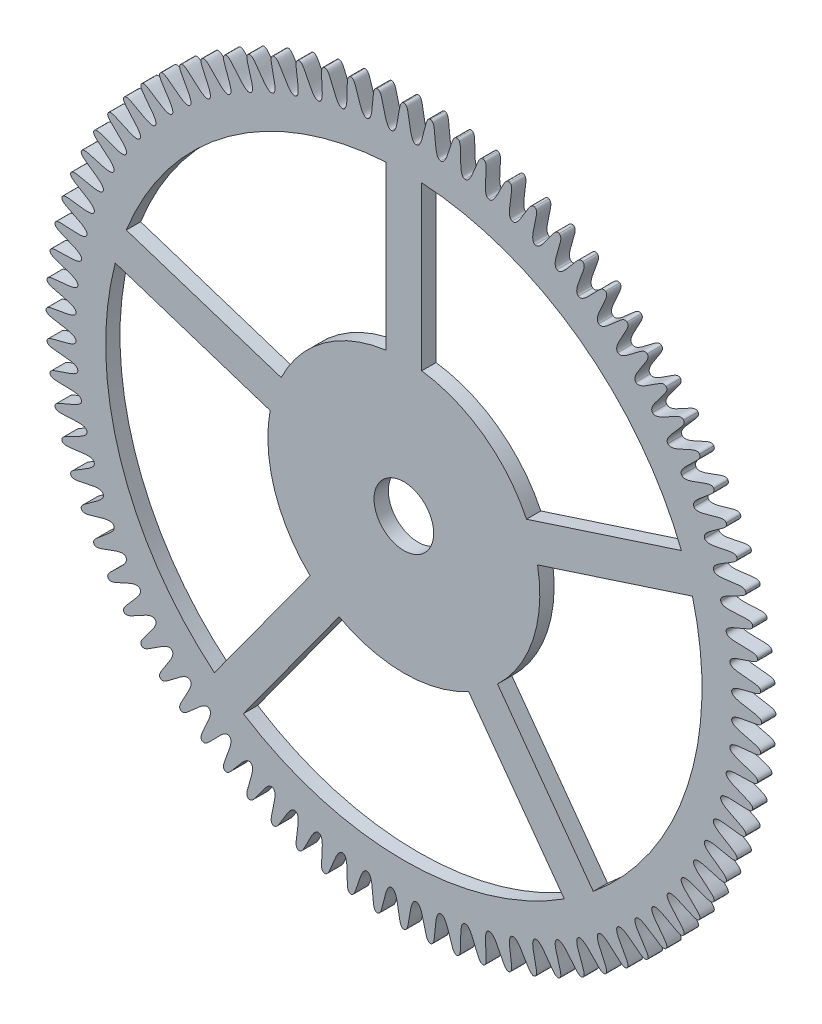
from build123d import *

# Parameters (mm, degrees)
BOSS_EXTRUDE1_84_TEETH_DEPTH = 0.24
CUT_EXTRUDE1_REACH           = 2.24
SKETCH2_R                    = 0.5


with BuildPart() as part:
    # Sketch1 → Boss-Extrude1 (84 teeth) (new body)
    with BuildSketch(Plane.XY):
        with BuildLine():
            add(Edge.make_bspline(
                [(0, 6), (0.062405482, 5.99994907), (0.073251994, 5.870714919), (0.116278173, 5.617573118), (0.146866227, 5.497572533), (0.205718544, 5.497943824)],
                knots=[0, 0, 0, 0, 0.435078789, 0.535078789, 1, 1, 1, 1], degree=3))
            add(Edge.make_bspline(
                [(0.448380562, 5.983222783), (0.386145772, 5.987835563), (0.365671908, 5.859773338), (0.303848729, 5.610554723), (0.264378551, 5.493175532), (0.205718544, 5.497943824)],
                knots=[0, 0, 0, 0, 0.435078789, 0.535078789, 1, 1, 1, 1], degree=3))
            add(Edge.make_bspline(
                [(0.448380562, 5.983222783), (0.510607739, 5.978508428), (0.511766242, 5.848825081), (0.535754801, 5.593175765), (0.557289669, 5.471224878), (0.616005169, 5.467197092)],
                knots=[0, 0, 0, 0, 0.435078789, 0.535078789, 1, 1, 1, 1], degree=3))
            add(Edge.make_bspline(
                [(0.894253597, 5.932984957), (0.832537542, 5.942235651), (0.802550825, 5.816061527), (0.722276386, 5.57215983), (0.674144817, 5.458058465), (0.616005169, 5.467197092)],
                knots=[0, 0, 0, 0, 0.435078789, 0.535078789, 1, 1, 1, 1], degree=3))
            add(Edge.make_bspline(
                [(0.894253597, 5.932984957), (0.955954471, 5.923633542), (0.947418486, 5.79422624), (0.95223527, 5.537499105), (0.964596521, 5.414279915), (1.022846844, 5.405875576)],
                knots=[0, 0, 0, 0, 0.435078789, 0.535078789, 1, 1, 1, 1], degree=3))
            add(Edge.make_bspline(
                [(1.335125604, 5.849567473), (1.274273425, 5.863404346), (1.234941553, 5.739823941), (1.13666478, 5.502603159), (1.080140991, 5.392417722), (1.022846844, 5.405875576)],
                knots=[0, 0, 0, 0, 0.435078789, 0.535078789, 1, 1, 1, 1], degree=3))
            add(Edge.make_bspline(
                [(1.335125604, 5.849567473), (1.395955117, 5.835631294), (1.377772381, 5.707223737), (1.363390454, 5.450854503), (1.366508958, 5.327056102), (1.423968345, 5.314322211)],
                knots=[0, 0, 0, 0, 0.435078789, 0.535078789, 1, 1, 1, 1], degree=3))
            add(Edge.make_bspline(
                [(1.768531046, 5.733436835), (1.708883053, 5.751782506), (1.660425986, 5.631486931), (1.544696484, 5.402273699), (1.480096579, 5.296620391), (1.423968345, 5.314322211)],
                knots=[0, 0, 0, 0, 0.435078789, 0.535078789, 1, 1, 1, 1], degree=3))
            add(Edge.make_bspline(
                [(1.768531046, 5.733436835), (1.828149016, 5.714993829), (1.800421214, 5.588304123), (1.766921005, 5.333726513), (1.760779323, 5.21004123), (1.817126437, 5.193049001)],
                knots=[0, 0, 0, 0, 0.435078789, 0.535078789, 1, 1, 1, 1], degree=3))
            add(Edge.make_bspline(
                [(2.192046146, 5.585242492), (2.133935915, 5.607994365), (2.076624644, 5.491656362), (1.944089618, 5.271732533), (1.871774866, 5.17120221), (1.817126437, 5.193049001)],
                knots=[0, 0, 0, 0, 0.435078789, 0.535078789, 1, 1, 1, 1], degree=3))
            add(Edge.make_bspline(
                [(2.192046146, 5.585242492), (2.250119164, 5.5623958), (2.213001361, 5.438132445), (2.160570216, 5.186770159), (2.145202696, 5.063889695), (2.20012242, 5.042734154)],
                knots=[0, 0, 0, 0, 0.435078789, 0.535078789, 1, 1, 1, 1], degree=3))
            add(Edge.make_bspline(
                [(2.603302435, 5.405813207), (2.547054941, 5.432844045), (2.481209974, 5.321114223), (2.332610615, 5.111709701), (2.252985429, 5.016864569), (2.20012242, 5.042734154)],
                knots=[0, 0, 0, 0, 0.435078789, 0.535078789, 1, 1, 1, 1], degree=3))
            add(Edge.make_bspline(
                [(2.603302435, 5.405813207), (2.659505734, 5.378690597), (2.613205507, 5.257548525), (2.542136643, 5.010807284), (2.517629225, 4.889418834), (2.570814427, 4.864218292)],
                knots=[0, 0, 0, 0, 0.435078789, 0.535078789, 1, 1, 1, 1], degree=3))
            add(Edge.make_bspline(
                [(3, 5.196152423), (2.945929802, 5.227311057), (2.871919371, 5.120814255), (2.708086707, 4.923100114), (2.621596383, 4.834470586), (2.570814427, 4.864218292)],
                knots=[0, 0, 0, 0, 0.435078789, 0.535078789, 1, 1, 1, 1], degree=3))
            add(Edge.make_bspline(
                [(3, 5.196152423), (3.054019268, 5.164905575), (2.998795547, 5.047562261), (2.909486411, 4.806821941), (2.87597615, 4.68760436), (2.927129397, 4.658499748)],
                knots=[0, 0, 0, 0, 0.435078789, 0.535078789, 1, 1, 1, 1], degree=3))
            add(Edge.make_bspline(
                [(3.379920348, 4.957432646), (3.32832983, 4.992544825), (3.246567831, 4.891876617), (3.068418079, 4.706958555), (2.975546308, 4.625040283), (2.927129397, 4.658499748)],
                knots=[0, 0, 0, 0, 0.435078789, 0.535078789, 1, 1, 1, 1], degree=3))
            add(Edge.make_bspline(
                [(3.379920348, 4.957432646), (3.431453488, 4.922236306), (3.367615107, 4.809347981), (3.26056515, 4.5759549), (3.21823945, 4.4595749), (3.267074672, 4.426728984)],
                knots=[0, 0, 0, 0, 0.435078789, 0.535078789, 1, 1, 1, 1], degree=3))
            add(Edge.make_bspline(
                [(3.740938811, 4.690988895), (3.692116487, 4.729858258), (3.603060166, 4.63558162), (3.411589613, 4.464493774), (3.31285577, 4.389744878), (3.267074672, 4.426728984)],
                knots=[0, 0, 0, 0, 0.435078789, 0.535078789, 1, 1, 1, 1], degree=3))
            add(Edge.make_bspline(
                [(3.740938811, 4.690988895), (3.789697627, 4.652039895), (3.717601597, 4.544237877), (3.593409487, 4.319497263), (3.542505049, 4.206605689), (3.588749139, 4.170202156)],
                knots=[0, 0, 0, 0, 0.435078789, 0.535078789, 1, 1, 1, 1], degree=3))
            add(Edge.make_bspline(
                [(4.081036427, 4.398311231), (4.03525533, 4.440720404), (3.939402727, 4.35336257), (3.735682154, 4.197061733), (3.631638399, 4.129900239), (3.588749139, 4.170202156)],
                knots=[0, 0, 0, 0, 0.435078789, 0.535078789, 1, 1, 1, 1], degree=3))
            add(Edge.make_bspline(
                [(4.081036427, 4.398311231), (4.126748241, 4.355827389), (4.046797751, 4.253714551), (3.90615802, 4.038883246), (3.846959523, 3.930111433), (3.890353866, 3.890353866)],
                knots=[0, 0, 0, 0, 0.435078789, 0.535078789, 1, 1, 1, 1], degree=3))
            add(Edge.make_bspline(
                [(4.398311231, 4.081036427), (4.355827389, 4.126748241), (4.253714551, 4.046797751), (4.038883246, 3.90615802), (3.930111433, 3.846959523), (3.890353866, 3.890353866)],
                knots=[0, 0, 0, 0, 0.435078789, 0.535078789, 1, 1, 1, 1], degree=3))
            add(Edge.make_bspline(
                [(4.398311231, 4.081036427), (4.440720404, 4.03525533), (4.35336257, 3.939402727), (4.197061733, 3.735682154), (4.129900239, 3.631638399), (4.170202156, 3.588749139)],
                knots=[0, 0, 0, 0, 0.435078789, 0.535078789, 1, 1, 1, 1], degree=3))
            add(Edge.make_bspline(
                [(4.690988895, 3.740938811), (4.652039895, 3.789697627), (4.544237877, 3.717601597), (4.319497263, 3.593409487), (4.206605689, 3.542505049), (4.170202156, 3.588749139)],
                knots=[0, 0, 0, 0, 0.435078789, 0.535078789, 1, 1, 1, 1], degree=3))
            add(Edge.make_bspline(
                [(4.690988895, 3.740938811), (4.729858258, 3.692116487), (4.63558162, 3.603060166), (4.464493774, 3.411589613), (4.389744878, 3.31285577), (4.426728984, 3.267074672)],
                knots=[0, 0, 0, 0, 0.435078789, 0.535078789, 1, 1, 1, 1], degree=3))
            add(Edge.make_bspline(
                [(4.957432646, 3.379920348), (4.922236306, 3.431453488), (4.809347981, 3.367615107), (4.5759549, 3.26056515), (4.4595749, 3.21823945), (4.426728984, 3.267074672)],
                knots=[0, 0, 0, 0, 0.435078789, 0.535078789, 1, 1, 1, 1], degree=3))
            add(Edge.make_bspline(
                [(4.957432646, 3.379920348), (4.992544825, 3.32832983), (4.891876617, 3.246567831), (4.706958555, 3.068418079), (4.625040283, 2.975546308), (4.658499748, 2.927129397)],
                knots=[0, 0, 0, 0, 0.435078789, 0.535078789, 1, 1, 1, 1], degree=3))
            add(Edge.make_bspline(
                [(5.196152423, 3), (5.164905575, 3.054019268), (5.047562261, 2.998795547), (4.806821941, 2.909486411), (4.68760436, 2.87597615), (4.658499748, 2.927129397)],
                knots=[0, 0, 0, 0, 0.435078789, 0.535078789, 1, 1, 1, 1], degree=3))
            add(Edge.make_bspline(
                [(5.196152423, 3), (5.227311057, 2.945929802), (5.120814255, 2.871919371), (4.923100114, 2.708086707), (4.834470586, 2.621596383), (4.864218292, 2.570814427)],
                knots=[0, 0, 0, 0, 0.435078789, 0.535078789, 1, 1, 1, 1], degree=3))
            add(Edge.make_bspline(
                [(5.405813207, 2.603302435), (5.378690597, 2.659505734), (5.257548525, 2.613205507), (5.010807284, 2.542136643), (4.889418834, 2.517629225), (4.864218292, 2.570814427)],
                knots=[0, 0, 0, 0, 0.435078789, 0.535078789, 1, 1, 1, 1], degree=3))
            add(Edge.make_bspline(
                [(5.405813207, 2.603302435), (5.432844045, 2.547054941), (5.321114223, 2.481209974), (5.111709701, 2.332610615), (5.016864569, 2.252985429), (5.042734154, 2.20012242)],
                knots=[0, 0, 0, 0, 0.435078789, 0.535078789, 1, 1, 1, 1], degree=3))
            add(Edge.make_bspline(
                [(5.585242492, 2.192046146), (5.5623958, 2.250119164), (5.438132445, 2.213001361), (5.186770159, 2.160570216), (5.063889695, 2.145202696), (5.042734154, 2.20012242)],
                knots=[0, 0, 0, 0, 0.435078789, 0.535078789, 1, 1, 1, 1], degree=3))
            add(Edge.make_bspline(
                [(5.585242492, 2.192046146), (5.607994365, 2.133935915), (5.491656362, 2.076624644), (5.271732533, 1.944089618), (5.17120221, 1.871774866), (5.193049001, 1.817126437)],
                knots=[0, 0, 0, 0, 0.435078789, 0.535078789, 1, 1, 1, 1], degree=3))
            add(Edge.make_bspline(
                [(5.733436835, 1.768531046), (5.714993829, 1.828149016), (5.588304123, 1.800421214), (5.333726513, 1.766921005), (5.21004123, 1.760779323), (5.193049001, 1.817126437)],
                knots=[0, 0, 0, 0, 0.435078789, 0.535078789, 1, 1, 1, 1], degree=3))
            add(Edge.make_bspline(
                [(5.733436835, 1.768531046), (5.751782506, 1.708883053), (5.631486931, 1.660425986), (5.402273699, 1.544696484), (5.296620391, 1.480096579), (5.314322211, 1.423968345)],
                knots=[0, 0, 0, 0, 0.435078789, 0.535078789, 1, 1, 1, 1], degree=3))
            add(Edge.make_bspline(
                [(5.849567473, 1.335125604), (5.835631294, 1.395955117), (5.707223737, 1.377772381), (5.450854503, 1.363390454), (5.327056102, 1.366508958), (5.314322211, 1.423968345)],
                knots=[0, 0, 0, 0, 0.435078789, 0.535078789, 1, 1, 1, 1], degree=3))
            add(Edge.make_bspline(
                [(5.849567473, 1.335125604), (5.863404346, 1.274273425), (5.739823941, 1.234941553), (5.502603159, 1.13666478), (5.392417722, 1.080140991), (5.405875576, 1.022846844)],
                knots=[0, 0, 0, 0, 0.435078789, 0.535078789, 1, 1, 1, 1], degree=3))
            add(Edge.make_bspline(
                [(5.932984957, 0.894253597), (5.923633542, 0.955954471), (5.79422624, 0.947418486), (5.537499105, 0.95223527), (5.414279915, 0.964596521), (5.405875576, 1.022846844)],
                knots=[0, 0, 0, 0, 0.435078789, 0.535078789, 1, 1, 1, 1], degree=3))
            add(Edge.make_bspline(
                [(5.932984957, 0.894253597), (5.942235651, 0.832537542), (5.816061527, 0.802550825), (5.57215983, 0.722276386), (5.458058465, 0.674144817), (5.467197092, 0.616005169)],
                knots=[0, 0, 0, 0, 0.435078789, 0.535078789, 1, 1, 1, 1], degree=3))
            add(Edge.make_bspline(
                [(5.983222783, 0.448380562), (5.978508428, 0.510607739), (5.848825081, 0.511766242), (5.593175765, 0.535754801), (5.471224878, 0.557289669), (5.467197092, 0.616005169)],
                knots=[0, 0, 0, 0, 0.435078789, 0.535078789, 1, 1, 1, 1], degree=3))
            add(Edge.make_bspline(
                [(5.983222783, 0.448380562), (5.987835563, 0.386145772), (5.859773338, 0.365671908), (5.610554723, 0.303848729), (5.493175532, 0.264378551), (5.497943824, 0.205718544)],
                knots=[0, 0, 0, 0, 0.435078789, 0.535078789, 1, 1, 1, 1], degree=3))
            add(Edge.make_bspline(
                [(6, 0), (5.99994907, 0.062405482), (5.870714919, 0.073251994), (5.617573118, 0.116278173), (5.497572533, 0.146866227), (5.497943824, 0.205718544)],
                knots=[0, 0, 0, 0, 0.435078789, 0.535078789, 1, 1, 1, 1], degree=3))
            add(Edge.make_bspline(
                [(6, 0), (5.99994907, -0.062405482), (5.870714919, -0.073251994), (5.617573118, -0.116278173), (5.497572533, -0.146866227), (5.497943824, -0.205718544)],
                knots=[0, 0, 0, 0, 0.435078789, 0.535078789, 1, 1, 1, 1], degree=3))
            add(Edge.make_bspline(
                [(5.983222783, -0.448380562), (5.987835563, -0.386145772), (5.859773338, -0.365671908), (5.610554723, -0.303848729), (5.493175532, -0.264378551), (5.497943824, -0.205718544)],
                knots=[0, 0, 0, 0, 0.435078789, 0.535078789, 1, 1, 1, 1], degree=3))
            add(Edge.make_bspline(
                [(5.983222783, -0.448380562), (5.978508428, -0.510607739), (5.848825081, -0.511766242), (5.593175765, -0.535754801), (5.471224878, -0.557289669), (5.467197092, -0.616005169)],
                knots=[0, 0, 0, 0, 0.435078789, 0.535078789, 1, 1, 1, 1], degree=3))
            add(Edge.make_bspline(
                [(5.932984957, -0.894253597), (5.942235651, -0.832537542), (5.816061527, -0.802550825), (5.57215983, -0.722276386), (5.458058465, -0.674144817), (5.467197092, -0.616005169)],
                knots=[0, 0, 0, 0, 0.435078789, 0.535078789, 1, 1, 1, 1], degree=3))
            add(Edge.make_bspline(
                [(5.932984957, -0.894253597), (5.923633542, -0.955954471), (5.79422624, -0.947418486), (5.537499105, -0.95223527), (5.414279915, -0.964596521), (5.405875576, -1.022846844)],
                knots=[0, 0, 0, 0, 0.435078789, 0.535078789, 1, 1, 1, 1], degree=3))
            add(Edge.make_bspline(
                [(5.849567473, -1.335125604), (5.863404346, -1.274273425), (5.739823941, -1.234941553), (5.502603159, -1.13666478), (5.392417722, -1.080140991), (5.405875576, -1.022846844)],
                knots=[0, 0, 0, 0, 0.435078789, 0.535078789, 1, 1, 1, 1], degree=3))
            add(Edge.make_bspline(
                [(5.849567473, -1.335125604), (5.835631294, -1.395955117), (5.707223737, -1.377772381), (5.450854503, -1.363390454), (5.327056102, -1.366508958), (5.314322211, -1.423968345)],
                knots=[0, 0, 0, 0, 0.435078789, 0.535078789, 1, 1, 1, 1], degree=3))
            add(Edge.make_bspline(
                [(5.733436835, -1.768531046), (5.751782506, -1.708883053), (5.631486931, -1.660425986), (5.402273699, -1.544696484), (5.296620391, -1.480096579), (5.314322211, -1.423968345)],
                knots=[0, 0, 0, 0, 0.435078789, 0.535078789, 1, 1, 1, 1], degree=3))
            add(Edge.make_bspline(
                [(5.733436835, -1.768531046), (5.714993829, -1.828149016), (5.588304123, -1.800421214), (5.333726513, -1.766921005), (5.21004123, -1.760779323), (5.193049001, -1.817126437)],
                knots=[0, 0, 0, 0, 0.435078789, 0.535078789, 1, 1, 1, 1], degree=3))
            add(Edge.make_bspline(
                [(5.585242492, -2.192046146), (5.607994365, -2.133935915), (5.491656362, -2.076624644), (5.271732533, -1.944089618), (5.17120221, -1.871774866), (5.193049001, -1.817126437)],
                knots=[0, 0, 0, 0, 0.435078789, 0.535078789, 1, 1, 1, 1], degree=3))
            add(Edge.make_bspline(
                [(5.585242492, -2.192046146), (5.5623958, -2.250119164), (5.438132445, -2.213001361), (5.186770159, -2.160570216), (5.063889695, -2.145202696), (5.042734154, -2.20012242)],
                knots=[0, 0, 0, 0, 0.435078789, 0.535078789, 1, 1, 1, 1], degree=3))
            add(Edge.make_bspline(
                [(5.405813207, -2.603302435), (5.432844045, -2.547054941), (5.321114223, -2.481209974), (5.111709701, -2.332610615), (5.016864569, -2.252985429), (5.042734154, -2.20012242)],
                knots=[0, 0, 0, 0, 0.435078789, 0.535078789, 1, 1, 1, 1], degree=3))
            add(Edge.make_bspline(
                [(5.405813207, -2.603302435), (5.378690597, -2.659505734), (5.257548525, -2.613205507), (5.010807284, -2.542136643), (4.889418834, -2.517629225), (4.864218292, -2.570814427)],
                knots=[0, 0, 0, 0, 0.435078789, 0.535078789, 1, 1, 1, 1], degree=3))
            add(Edge.make_bspline(
                [(5.196152423, -3), (5.227311057, -2.945929802), (5.120814255, -2.871919371), (4.923100114, -2.708086707), (4.834470586, -2.621596383), (4.864218292, -2.570814427)],
                knots=[0, 0, 0, 0, 0.435078789, 0.535078789, 1, 1, 1, 1], degree=3))
            add(Edge.make_bspline(
                [(5.196152423, -3), (5.164905575, -3.054019268), (5.047562261, -2.998795547), (4.806821941, -2.909486411), (4.68760436, -2.87597615), (4.658499748, -2.927129397)],
                knots=[0, 0, 0, 0, 0.435078789, 0.535078789, 1, 1, 1, 1], degree=3))
            add(Edge.make_bspline(
                [(4.957432646, -3.379920348), (4.992544825, -3.32832983), (4.891876617, -3.246567831), (4.706958555, -3.068418079), (4.625040283, -2.975546308), (4.658499748, -2.927129397)],
                knots=[0, 0, 0, 0, 0.435078789, 0.535078789, 1, 1, 1, 1], degree=3))
            add(Edge.make_bspline(
                [(4.957432646, -3.379920348), (4.922236306, -3.431453488), (4.809347981, -3.367615107), (4.5759549, -3.26056515), (4.4595749, -3.21823945), (4.426728984, -3.267074672)],
                knots=[0, 0, 0, 0, 0.435078789, 0.535078789, 1, 1, 1, 1], degree=3))
            add(Edge.make_bspline(
                [(4.690988895, -3.740938811), (4.729858258, -3.692116487), (4.63558162, -3.603060166), (4.464493774, -3.411589613), (4.389744878, -3.31285577), (4.426728984, -3.267074672)],
                knots=[0, 0, 0, 0, 0.435078789, 0.535078789, 1, 1, 1, 1], degree=3))
            add(Edge.make_bspline(
                [(4.690988895, -3.740938811), (4.652039895, -3.789697627), (4.544237877, -3.717601597), (4.319497263, -3.593409487), (4.206605689, -3.542505049), (4.170202156, -3.588749139)],
                knots=[0, 0, 0, 0, 0.435078789, 0.535078789, 1, 1, 1, 1], degree=3))
            add(Edge.make_bspline(
                [(4.398311231, -4.081036427), (4.440720404, -4.03525533), (4.35336257, -3.939402727), (4.197061733, -3.735682154), (4.129900239, -3.631638399), (4.170202156, -3.588749139)],
                knots=[0, 0, 0, 0, 0.435078789, 0.535078789, 1, 1, 1, 1], degree=3))
            add(Edge.make_bspline(
                [(4.398311231, -4.081036427), (4.355827389, -4.126748241), (4.253714551, -4.046797751), (4.038883246, -3.90615802), (3.930111433, -3.846959523), (3.890353866, -3.890353866)],
                knots=[0, 0, 0, 0, 0.435078789, 0.535078789, 1, 1, 1, 1], degree=3))
            add(Edge.make_bspline(
                [(4.081036427, -4.398311231), (4.126748241, -4.355827389), (4.046797751, -4.253714551), (3.90615802, -4.038883246), (3.846959523, -3.930111433), (3.890353866, -3.890353866)],
                knots=[0, 0, 0, 0, 0.435078789, 0.535078789, 1, 1, 1, 1], degree=3))
            add(Edge.make_bspline(
                [(4.081036427, -4.398311231), (4.03525533, -4.440720404), (3.939402727, -4.35336257), (3.735682154, -4.197061733), (3.631638399, -4.129900239), (3.588749139, -4.170202156)],
                knots=[0, 0, 0, 0, 0.435078789, 0.535078789, 1, 1, 1, 1], degree=3))
            add(Edge.make_bspline(
                [(3.740938811, -4.690988895), (3.789697627, -4.652039895), (3.717601597, -4.544237877), (3.593409487, -4.319497263), (3.542505049, -4.206605689), (3.588749139, -4.170202156)],
                knots=[0, 0, 0, 0, 0.435078789, 0.535078789, 1, 1, 1, 1], degree=3))
            add(Edge.make_bspline(
                [(3.740938811, -4.690988895), (3.692116487, -4.729858258), (3.603060166, -4.63558162), (3.411589613, -4.464493774), (3.31285577, -4.389744878), (3.267074672, -4.426728984)],
                knots=[0, 0, 0, 0, 0.435078789, 0.535078789, 1, 1, 1, 1], degree=3))
            add(Edge.make_bspline(
                [(3.379920348, -4.957432646), (3.431453488, -4.922236306), (3.367615107, -4.809347981), (3.26056515, -4.5759549), (3.21823945, -4.4595749), (3.267074672, -4.426728984)],
                knots=[0, 0, 0, 0, 0.435078789, 0.535078789, 1, 1, 1, 1], degree=3))
            add(Edge.make_bspline(
                [(3.379920348, -4.957432646), (3.32832983, -4.992544825), (3.246567831, -4.891876617), (3.068418079, -4.706958555), (2.975546308, -4.625040283), (2.927129397, -4.658499748)],
                knots=[0, 0, 0, 0, 0.435078789, 0.535078789, 1, 1, 1, 1], degree=3))
            add(Edge.make_bspline(
                [(3, -5.196152423), (3.054019268, -5.164905575), (2.998795547, -5.047562261), (2.909486411, -4.806821941), (2.87597615, -4.68760436), (2.927129397, -4.658499748)],
                knots=[0, 0, 0, 0, 0.435078789, 0.535078789, 1, 1, 1, 1], degree=3))
            add(Edge.make_bspline(
                [(3, -5.196152423), (2.945929802, -5.227311057), (2.871919371, -5.120814255), (2.708086707, -4.923100114), (2.621596383, -4.834470586), (2.570814427, -4.864218292)],
                knots=[0, 0, 0, 0, 0.435078789, 0.535078789, 1, 1, 1, 1], degree=3))
            add(Edge.make_bspline(
                [(2.603302435, -5.405813207), (2.659505734, -5.378690597), (2.613205507, -5.257548525), (2.542136643, -5.010807284), (2.517629225, -4.889418834), (2.570814427, -4.864218292)],
                knots=[0, 0, 0, 0, 0.435078789, 0.535078789, 1, 1, 1, 1], degree=3))
            add(Edge.make_bspline(
                [(2.603302435, -5.405813207), (2.547054941, -5.432844045), (2.481209974, -5.321114223), (2.332610615, -5.111709701), (2.252985429, -5.016864569), (2.20012242, -5.042734154)],
                knots=[0, 0, 0, 0, 0.435078789, 0.535078789, 1, 1, 1, 1], degree=3))
            add(Edge.make_bspline(
                [(2.192046146, -5.585242492), (2.250119164, -5.5623958), (2.213001361, -5.438132445), (2.160570216, -5.186770159), (2.145202696, -5.063889695), (2.20012242, -5.042734154)],
                knots=[0, 0, 0, 0, 0.435078789, 0.535078789, 1, 1, 1, 1], degree=3))
            add(Edge.make_bspline(
                [(2.192046146, -5.585242492), (2.133935915, -5.607994365), (2.076624644, -5.491656362), (1.944089618, -5.271732533), (1.871774866, -5.17120221), (1.817126437, -5.193049001)],
                knots=[0, 0, 0, 0, 0.435078789, 0.535078789, 1, 1, 1, 1], degree=3))
            add(Edge.make_bspline(
                [(1.768531046, -5.733436835), (1.828149016, -5.714993829), (1.800421214, -5.588304123), (1.766921005, -5.333726513), (1.760779323, -5.21004123), (1.817126437, -5.193049001)],
                knots=[0, 0, 0, 0, 0.435078789, 0.535078789, 1, 1, 1, 1], degree=3))
            add(Edge.make_bspline(
                [(1.768531046, -5.733436835), (1.708883053, -5.751782506), (1.660425986, -5.631486931), (1.544696484, -5.402273699), (1.480096579, -5.296620391), (1.423968345, -5.314322211)],
                knots=[0, 0, 0, 0, 0.435078789, 0.535078789, 1, 1, 1, 1], degree=3))
            add(Edge.make_bspline(
                [(1.335125604, -5.849567473), (1.395955117, -5.835631294), (1.377772381, -5.707223737), (1.363390454, -5.450854503), (1.366508958, -5.327056102), (1.423968345, -5.314322211)],
                knots=[0, 0, 0, 0, 0.435078789, 0.535078789, 1, 1, 1, 1], degree=3))
            add(Edge.make_bspline(
                [(1.335125604, -5.849567473), (1.274273425, -5.863404346), (1.234941553, -5.739823941), (1.13666478, -5.502603159), (1.080140991, -5.392417722), (1.022846844, -5.405875576)],
                knots=[0, 0, 0, 0, 0.435078789, 0.535078789, 1, 1, 1, 1], degree=3))
            add(Edge.make_bspline(
                [(0.894253597, -5.932984957), (0.955954471, -5.923633542), (0.947418486, -5.79422624), (0.95223527, -5.537499105), (0.964596521, -5.414279915), (1.022846844, -5.405875576)],
                knots=[0, 0, 0, 0, 0.435078789, 0.535078789, 1, 1, 1, 1], degree=3))
            add(Edge.make_bspline(
                [(0.894253597, -5.932984957), (0.832537542, -5.942235651), (0.802550825, -5.816061527), (0.722276386, -5.57215983), (0.674144817, -5.458058465), (0.616005169, -5.467197092)],
                knots=[0, 0, 0, 0, 0.435078789, 0.535078789, 1, 1, 1, 1], degree=3))
            add(Edge.make_bspline(
                [(0.448380562, -5.983222783), (0.510607739, -5.978508428), (0.511766242, -5.848825081), (0.535754801, -5.593175765), (0.557289669, -5.471224878), (0.616005169, -5.467197092)],
                knots=[0, 0, 0, 0, 0.435078789, 0.535078789, 1, 1, 1, 1], degree=3))
            add(Edge.make_bspline(
                [(0.448380562, -5.983222783), (0.386145772, -5.987835563), (0.365671908, -5.859773338), (0.303848729, -5.610554723), (0.264378551, -5.493175532), (0.205718544, -5.497943824)],
                knots=[0, 0, 0, 0, 0.435078789, 0.535078789, 1, 1, 1, 1], degree=3))
            add(Edge.make_bspline(
                [(0, -6), (0.062405482, -5.99994907), (0.073251994, -5.870714919), (0.116278173, -5.617573118), (0.146866227, -5.497572533), (0.205718544, -5.497943824)],
                knots=[0, 0, 0, 0, 0.435078789, 0.535078789, 1, 1, 1, 1], degree=3))
            add(Edge.make_bspline(
                [(0, -6), (-0.062405482, -5.99994907), (-0.073251994, -5.870714919), (-0.116278173, -5.617573118), (-0.146866227, -5.497572533), (-0.205718544, -5.497943824)],
                knots=[0, 0, 0, 0, 0.435078789, 0.535078789, 1, 1, 1, 1], degree=3))
            add(Edge.make_bspline(
                [(-0.448380562, -5.983222783), (-0.386145772, -5.987835563), (-0.365671908, -5.859773338), (-0.303848729, -5.610554723), (-0.264378551, -5.493175532), (-0.205718544, -5.497943824)],
                knots=[0, 0, 0, 0, 0.435078789, 0.535078789, 1, 1, 1, 1], degree=3))
            add(Edge.make_bspline(
                [(-0.448380562, -5.983222783), (-0.510607739, -5.978508428), (-0.511766242, -5.848825081), (-0.535754801, -5.593175765), (-0.557289669, -5.471224878), (-0.616005169, -5.467197092)],
                knots=[0, 0, 0, 0, 0.435078789, 0.535078789, 1, 1, 1, 1], degree=3))
            add(Edge.make_bspline(
                [(-0.894253597, -5.932984957), (-0.832537542, -5.942235651), (-0.802550825, -5.816061527), (-0.722276386, -5.57215983), (-0.674144817, -5.458058465), (-0.616005169, -5.467197092)],
                knots=[0, 0, 0, 0, 0.435078789, 0.535078789, 1, 1, 1, 1], degree=3))
            add(Edge.make_bspline(
                [(-0.894253597, -5.932984957), (-0.955954471, -5.923633542), (-0.947418486, -5.79422624), (-0.95223527, -5.537499105), (-0.964596521, -5.414279915), (-1.022846844, -5.405875576)],
                knots=[0, 0, 0, 0, 0.435078789, 0.535078789, 1, 1, 1, 1], degree=3))
            add(Edge.make_bspline(
                [(-1.335125604, -5.849567473), (-1.274273425, -5.863404346), (-1.234941553, -5.739823941), (-1.13666478, -5.502603159), (-1.080140991, -5.392417722), (-1.022846844, -5.405875576)],
                knots=[0, 0, 0, 0, 0.435078789, 0.535078789, 1, 1, 1, 1], degree=3))
            add(Edge.make_bspline(
                [(-1.335125604, -5.849567473), (-1.395955117, -5.835631294), (-1.377772381, -5.707223737), (-1.363390454, -5.450854503), (-1.366508958, -5.327056102), (-1.423968345, -5.314322211)],
                knots=[0, 0, 0, 0, 0.435078789, 0.535078789, 1, 1, 1, 1], degree=3))
            add(Edge.make_bspline(
                [(-1.768531046, -5.733436835), (-1.708883053, -5.751782506), (-1.660425986, -5.631486931), (-1.544696484, -5.402273699), (-1.480096579, -5.296620391), (-1.423968345, -5.314322211)],
                knots=[0, 0, 0, 0, 0.435078789, 0.535078789, 1, 1, 1, 1], degree=3))
            add(Edge.make_bspline(
                [(-1.768531046, -5.733436835), (-1.828149016, -5.714993829), (-1.800421214, -5.588304123), (-1.766921005, -5.333726513), (-1.760779323, -5.21004123), (-1.817126437, -5.193049001)],
                knots=[0, 0, 0, 0, 0.435078789, 0.535078789, 1, 1, 1, 1], degree=3))
            add(Edge.make_bspline(
                [(-2.192046146, -5.585242492), (-2.133935915, -5.607994365), (-2.076624644, -5.491656362), (-1.944089618, -5.271732533), (-1.871774866, -5.17120221), (-1.817126437, -5.193049001)],
                knots=[0, 0, 0, 0, 0.435078789, 0.535078789, 1, 1, 1, 1], degree=3))
            add(Edge.make_bspline(
                [(-2.192046146, -5.585242492), (-2.250119164, -5.5623958), (-2.213001361, -5.438132445), (-2.160570216, -5.186770159), (-2.145202696, -5.063889695), (-2.20012242, -5.042734154)],
                knots=[0, 0, 0, 0, 0.435078789, 0.535078789, 1, 1, 1, 1], degree=3))
            add(Edge.make_bspline(
                [(-2.603302435, -5.405813207), (-2.547054941, -5.432844045), (-2.481209974, -5.321114223), (-2.332610615, -5.111709701), (-2.252985429, -5.016864569), (-2.20012242, -5.042734154)],
                knots=[0, 0, 0, 0, 0.435078789, 0.535078789, 1, 1, 1, 1], degree=3))
            add(Edge.make_bspline(
                [(-2.603302435, -5.405813207), (-2.659505734, -5.378690597), (-2.613205507, -5.257548525), (-2.542136643, -5.010807284), (-2.517629225, -4.889418834), (-2.570814427, -4.864218292)],
                knots=[0, 0, 0, 0, 0.435078789, 0.535078789, 1, 1, 1, 1], degree=3))
            add(Edge.make_bspline(
                [(-3, -5.196152423), (-2.945929802, -5.227311057), (-2.871919371, -5.120814255), (-2.708086707, -4.923100114), (-2.621596383, -4.834470586), (-2.570814427, -4.864218292)],
                knots=[0, 0, 0, 0, 0.435078789, 0.535078789, 1, 1, 1, 1], degree=3))
            add(Edge.make_bspline(
                [(-3, -5.196152423), (-3.054019268, -5.164905575), (-2.998795547, -5.047562261), (-2.909486411, -4.806821941), (-2.87597615, -4.68760436), (-2.927129397, -4.658499748)],
                knots=[0, 0, 0, 0, 0.435078789, 0.535078789, 1, 1, 1, 1], degree=3))
            add(Edge.make_bspline(
                [(-3.379920348, -4.957432646), (-3.32832983, -4.992544825), (-3.246567831, -4.891876617), (-3.068418079, -4.706958555), (-2.975546308, -4.625040283), (-2.927129397, -4.658499748)],
                knots=[0, 0, 0, 0, 0.435078789, 0.535078789, 1, 1, 1, 1], degree=3))
            add(Edge.make_bspline(
                [(-3.379920348, -4.957432646), (-3.431453488, -4.922236306), (-3.367615107, -4.809347981), (-3.26056515, -4.5759549), (-3.21823945, -4.4595749), (-3.267074672, -4.426728984)],
                knots=[0, 0, 0, 0, 0.435078789, 0.535078789, 1, 1, 1, 1], degree=3))
            add(Edge.make_bspline(
                [(-3.740938811, -4.690988895), (-3.692116487, -4.729858258), (-3.603060166, -4.63558162), (-3.411589613, -4.464493774), (-3.31285577, -4.389744878), (-3.267074672, -4.426728984)],
                knots=[0, 0, 0, 0, 0.435078789, 0.535078789, 1, 1, 1, 1], degree=3))
            add(Edge.make_bspline(
                [(-3.740938811, -4.690988895), (-3.789697627, -4.652039895), (-3.717601597, -4.544237877), (-3.593409487, -4.319497263), (-3.542505049, -4.206605689), (-3.588749139, -4.170202156)],
                knots=[0, 0, 0, 0, 0.435078789, 0.535078789, 1, 1, 1, 1], degree=3))
            add(Edge.make_bspline(
                [(-4.081036427, -4.398311231), (-4.03525533, -4.440720404), (-3.939402727, -4.35336257), (-3.735682154, -4.197061733), (-3.631638399, -4.129900239), (-3.588749139, -4.170202156)],
                knots=[0, 0, 0, 0, 0.435078789, 0.535078789, 1, 1, 1, 1], degree=3))
            add(Edge.make_bspline(
                [(-4.081036427, -4.398311231), (-4.126748241, -4.355827389), (-4.046797751, -4.253714551), (-3.90615802, -4.038883246), (-3.846959523, -3.930111433), (-3.890353866, -3.890353866)],
                knots=[0, 0, 0, 0, 0.435078789, 0.535078789, 1, 1, 1, 1], degree=3))
            add(Edge.make_bspline(
                [(-4.398311231, -4.081036427), (-4.355827389, -4.126748241), (-4.253714551, -4.046797751), (-4.038883246, -3.90615802), (-3.930111433, -3.846959523), (-3.890353866, -3.890353866)],
                knots=[0, 0, 0, 0, 0.435078789, 0.535078789, 1, 1, 1, 1], degree=3))
            add(Edge.make_bspline(
                [(-4.398311231, -4.081036427), (-4.440720404, -4.03525533), (-4.35336257, -3.939402727), (-4.197061733, -3.735682154), (-4.129900239, -3.631638399), (-4.170202156, -3.588749139)],
                knots=[0, 0, 0, 0, 0.435078789, 0.535078789, 1, 1, 1, 1], degree=3))
            add(Edge.make_bspline(
                [(-4.690988895, -3.740938811), (-4.652039895, -3.789697627), (-4.544237877, -3.717601597), (-4.319497263, -3.593409487), (-4.206605689, -3.542505049), (-4.170202156, -3.588749139)],
                knots=[0, 0, 0, 0, 0.435078789, 0.535078789, 1, 1, 1, 1], degree=3))
            add(Edge.make_bspline(
                [(-4.690988895, -3.740938811), (-4.729858258, -3.692116487), (-4.63558162, -3.603060166), (-4.464493774, -3.411589613), (-4.389744878, -3.31285577), (-4.426728984, -3.267074672)],
                knots=[0, 0, 0, 0, 0.435078789, 0.535078789, 1, 1, 1, 1], degree=3))
            add(Edge.make_bspline(
                [(-4.957432646, -3.379920348), (-4.922236306, -3.431453488), (-4.809347981, -3.367615107), (-4.5759549, -3.26056515), (-4.4595749, -3.21823945), (-4.426728984, -3.267074672)],
                knots=[0, 0, 0, 0, 0.435078789, 0.535078789, 1, 1, 1, 1], degree=3))
            add(Edge.make_bspline(
                [(-4.957432646, -3.379920348), (-4.992544825, -3.32832983), (-4.891876617, -3.246567831), (-4.706958555, -3.068418079), (-4.625040283, -2.975546308), (-4.658499748, -2.927129397)],
                knots=[0, 0, 0, 0, 0.435078789, 0.535078789, 1, 1, 1, 1], degree=3))
            add(Edge.make_bspline(
                [(-5.196152423, -3), (-5.164905575, -3.054019268), (-5.047562261, -2.998795547), (-4.806821941, -2.909486411), (-4.68760436, -2.87597615), (-4.658499748, -2.927129397)],
                knots=[0, 0, 0, 0, 0.435078789, 0.535078789, 1, 1, 1, 1], degree=3))
            add(Edge.make_bspline(
                [(-5.196152423, -3), (-5.227311057, -2.945929802), (-5.120814255, -2.871919371), (-4.923100114, -2.708086707), (-4.834470586, -2.621596383), (-4.864218292, -2.570814427)],
                knots=[0, 0, 0, 0, 0.435078789, 0.535078789, 1, 1, 1, 1], degree=3))
            add(Edge.make_bspline(
                [(-5.405813207, -2.603302435), (-5.378690597, -2.659505734), (-5.257548525, -2.613205507), (-5.010807284, -2.542136643), (-4.889418834, -2.517629225), (-4.864218292, -2.570814427)],
                knots=[0, 0, 0, 0, 0.435078789, 0.535078789, 1, 1, 1, 1], degree=3))
            add(Edge.make_bspline(
                [(-5.405813207, -2.603302435), (-5.432844045, -2.547054941), (-5.321114223, -2.481209974), (-5.111709701, -2.332610615), (-5.016864569, -2.252985429), (-5.042734154, -2.20012242)],
                knots=[0, 0, 0, 0, 0.435078789, 0.535078789, 1, 1, 1, 1], degree=3))
            add(Edge.make_bspline(
                [(-5.585242492, -2.192046146), (-5.5623958, -2.250119164), (-5.438132445, -2.213001361), (-5.186770159, -2.160570216), (-5.063889695, -2.145202696), (-5.042734154, -2.20012242)],
                knots=[0, 0, 0, 0, 0.435078789, 0.535078789, 1, 1, 1, 1], degree=3))
            add(Edge.make_bspline(
                [(-5.585242492, -2.192046146), (-5.607994365, -2.133935915), (-5.491656362, -2.076624644), (-5.271732533, -1.944089618), (-5.17120221, -1.871774866), (-5.193049001, -1.817126437)],
                knots=[0, 0, 0, 0, 0.435078789, 0.535078789, 1, 1, 1, 1], degree=3))
            add(Edge.make_bspline(
                [(-5.733436835, -1.768531046), (-5.714993829, -1.828149016), (-5.588304123, -1.800421214), (-5.333726513, -1.766921005), (-5.21004123, -1.760779323), (-5.193049001, -1.817126437)],
                knots=[0, 0, 0, 0, 0.435078789, 0.535078789, 1, 1, 1, 1], degree=3))
            add(Edge.make_bspline(
                [(-5.733436835, -1.768531046), (-5.751782506, -1.708883053), (-5.631486931, -1.660425986), (-5.402273699, -1.544696484), (-5.296620391, -1.480096579), (-5.314322211, -1.423968345)],
                knots=[0, 0, 0, 0, 0.435078789, 0.535078789, 1, 1, 1, 1], degree=3))
            add(Edge.make_bspline(
                [(-5.849567473, -1.335125604), (-5.835631294, -1.395955117), (-5.707223737, -1.377772381), (-5.450854503, -1.363390454), (-5.327056102, -1.366508958), (-5.314322211, -1.423968345)],
                knots=[0, 0, 0, 0, 0.435078789, 0.535078789, 1, 1, 1, 1], degree=3))
            add(Edge.make_bspline(
                [(-5.849567473, -1.335125604), (-5.863404346, -1.274273425), (-5.739823941, -1.234941553), (-5.502603159, -1.13666478), (-5.392417722, -1.080140991), (-5.405875576, -1.022846844)],
                knots=[0, 0, 0, 0, 0.435078789, 0.535078789, 1, 1, 1, 1], degree=3))
            add(Edge.make_bspline(
                [(-5.932984957, -0.894253597), (-5.923633542, -0.955954471), (-5.79422624, -0.947418486), (-5.537499105, -0.95223527), (-5.414279915, -0.964596521), (-5.405875576, -1.022846844)],
                knots=[0, 0, 0, 0, 0.435078789, 0.535078789, 1, 1, 1, 1], degree=3))
            add(Edge.make_bspline(
                [(-5.932984957, -0.894253597), (-5.942235651, -0.832537542), (-5.816061527, -0.802550825), (-5.57215983, -0.722276386), (-5.458058465, -0.674144817), (-5.467197092, -0.616005169)],
                knots=[0, 0, 0, 0, 0.435078789, 0.535078789, 1, 1, 1, 1], degree=3))
            add(Edge.make_bspline(
                [(-5.983222783, -0.448380562), (-5.978508428, -0.510607739), (-5.848825081, -0.511766242), (-5.593175765, -0.535754801), (-5.471224878, -0.557289669), (-5.467197092, -0.616005169)],
                knots=[0, 0, 0, 0, 0.435078789, 0.535078789, 1, 1, 1, 1], degree=3))
            add(Edge.make_bspline(
                [(-5.983222783, -0.448380562), (-5.987835563, -0.386145772), (-5.859773338, -0.365671908), (-5.610554723, -0.303848729), (-5.493175532, -0.264378551), (-5.497943824, -0.205718544)],
                knots=[0, 0, 0, 0, 0.435078789, 0.535078789, 1, 1, 1, 1], degree=3))
            add(Edge.make_bspline(
                [(-6, 0), (-5.99994907, -0.062405482), (-5.870714919, -0.073251994), (-5.617573118, -0.116278173), (-5.497572533, -0.146866227), (-5.497943824, -0.205718544)],
                knots=[0, 0, 0, 0, 0.435078789, 0.535078789, 1, 1, 1, 1], degree=3))
            add(Edge.make_bspline(
                [(-6, 0), (-5.99994907, 0.062405482), (-5.870714919, 0.073251994), (-5.617573118, 0.116278173), (-5.497572533, 0.146866227), (-5.497943824, 0.205718544)],
                knots=[0, 0, 0, 0, 0.435078789, 0.535078789, 1, 1, 1, 1], degree=3))
            add(Edge.make_bspline(
                [(-5.983222783, 0.448380562), (-5.987835563, 0.386145772), (-5.859773338, 0.365671908), (-5.610554723, 0.303848729), (-5.493175532, 0.264378551), (-5.497943824, 0.205718544)],
                knots=[0, 0, 0, 0, 0.435078789, 0.535078789, 1, 1, 1, 1], degree=3))
            add(Edge.make_bspline(
                [(-5.983222783, 0.448380562), (-5.978508428, 0.510607739), (-5.848825081, 0.511766242), (-5.593175765, 0.535754801), (-5.471224878, 0.557289669), (-5.467197092, 0.616005169)],
                knots=[0, 0, 0, 0, 0.435078789, 0.535078789, 1, 1, 1, 1], degree=3))
            add(Edge.make_bspline(
                [(-5.932984957, 0.894253597), (-5.942235651, 0.832537542), (-5.816061527, 0.802550825), (-5.57215983, 0.722276386), (-5.458058465, 0.674144817), (-5.467197092, 0.616005169)],
                knots=[0, 0, 0, 0, 0.435078789, 0.535078789, 1, 1, 1, 1], degree=3))
            add(Edge.make_bspline(
                [(-5.932984957, 0.894253597), (-5.923633542, 0.955954471), (-5.79422624, 0.947418486), (-5.537499105, 0.95223527), (-5.414279915, 0.964596521), (-5.405875576, 1.022846844)],
                knots=[0, 0, 0, 0, 0.435078789, 0.535078789, 1, 1, 1, 1], degree=3))
            add(Edge.make_bspline(
                [(-5.849567473, 1.335125604), (-5.863404346, 1.274273425), (-5.739823941, 1.234941553), (-5.502603159, 1.13666478), (-5.392417722, 1.080140991), (-5.405875576, 1.022846844)],
                knots=[0, 0, 0, 0, 0.435078789, 0.535078789, 1, 1, 1, 1], degree=3))
            add(Edge.make_bspline(
                [(-5.849567473, 1.335125604), (-5.835631294, 1.395955117), (-5.707223737, 1.377772381), (-5.450854503, 1.363390454), (-5.327056102, 1.366508958), (-5.314322211, 1.423968345)],
                knots=[0, 0, 0, 0, 0.435078789, 0.535078789, 1, 1, 1, 1], degree=3))
            add(Edge.make_bspline(
                [(-5.733436835, 1.768531046), (-5.751782506, 1.708883053), (-5.631486931, 1.660425986), (-5.402273699, 1.544696484), (-5.296620391, 1.480096579), (-5.314322211, 1.423968345)],
                knots=[0, 0, 0, 0, 0.435078789, 0.535078789, 1, 1, 1, 1], degree=3))
            add(Edge.make_bspline(
                [(-5.733436835, 1.768531046), (-5.714993829, 1.828149016), (-5.588304123, 1.800421214), (-5.333726513, 1.766921005), (-5.21004123, 1.760779323), (-5.193049001, 1.817126437)],
                knots=[0, 0, 0, 0, 0.435078789, 0.535078789, 1, 1, 1, 1], degree=3))
            add(Edge.make_bspline(
                [(-5.585242492, 2.192046146), (-5.607994365, 2.133935915), (-5.491656362, 2.076624644), (-5.271732533, 1.944089618), (-5.17120221, 1.871774866), (-5.193049001, 1.817126437)],
                knots=[0, 0, 0, 0, 0.435078789, 0.535078789, 1, 1, 1, 1], degree=3))
            add(Edge.make_bspline(
                [(-5.585242492, 2.192046146), (-5.5623958, 2.250119164), (-5.438132445, 2.213001361), (-5.186770159, 2.160570216), (-5.063889695, 2.145202696), (-5.042734154, 2.20012242)],
                knots=[0, 0, 0, 0, 0.435078789, 0.535078789, 1, 1, 1, 1], degree=3))
            add(Edge.make_bspline(
                [(-5.405813207, 2.603302435), (-5.432844045, 2.547054941), (-5.321114223, 2.481209974), (-5.111709701, 2.332610615), (-5.016864569, 2.252985429), (-5.042734154, 2.20012242)],
                knots=[0, 0, 0, 0, 0.435078789, 0.535078789, 1, 1, 1, 1], degree=3))
            add(Edge.make_bspline(
                [(-5.405813207, 2.603302435), (-5.378690597, 2.659505734), (-5.257548525, 2.613205507), (-5.010807284, 2.542136643), (-4.889418834, 2.517629225), (-4.864218292, 2.570814427)],
                knots=[0, 0, 0, 0, 0.435078789, 0.535078789, 1, 1, 1, 1], degree=3))
            add(Edge.make_bspline(
                [(-5.196152423, 3), (-5.227311057, 2.945929802), (-5.120814255, 2.871919371), (-4.923100114, 2.708086707), (-4.834470586, 2.621596383), (-4.864218292, 2.570814427)],
                knots=[0, 0, 0, 0, 0.435078789, 0.535078789, 1, 1, 1, 1], degree=3))
            add(Edge.make_bspline(
                [(-5.196152423, 3), (-5.164905575, 3.054019268), (-5.047562261, 2.998795547), (-4.806821941, 2.909486411), (-4.68760436, 2.87597615), (-4.658499748, 2.927129397)],
                knots=[0, 0, 0, 0, 0.435078789, 0.535078789, 1, 1, 1, 1], degree=3))
            add(Edge.make_bspline(
                [(-4.957432646, 3.379920348), (-4.992544825, 3.32832983), (-4.891876617, 3.246567831), (-4.706958555, 3.068418079), (-4.625040283, 2.975546308), (-4.658499748, 2.927129397)],
                knots=[0, 0, 0, 0, 0.435078789, 0.535078789, 1, 1, 1, 1], degree=3))
            add(Edge.make_bspline(
                [(-4.957432646, 3.379920348), (-4.922236306, 3.431453488), (-4.809347981, 3.367615107), (-4.5759549, 3.26056515), (-4.4595749, 3.21823945), (-4.426728984, 3.267074672)],
                knots=[0, 0, 0, 0, 0.435078789, 0.535078789, 1, 1, 1, 1], degree=3))
            add(Edge.make_bspline(
                [(-4.690988895, 3.740938811), (-4.729858258, 3.692116487), (-4.63558162, 3.603060166), (-4.464493774, 3.411589613), (-4.389744878, 3.31285577), (-4.426728984, 3.267074672)],
                knots=[0, 0, 0, 0, 0.435078789, 0.535078789, 1, 1, 1, 1], degree=3))
            add(Edge.make_bspline(
                [(-4.690988895, 3.740938811), (-4.652039895, 3.789697627), (-4.544237877, 3.717601597), (-4.319497263, 3.593409487), (-4.206605689, 3.542505049), (-4.170202156, 3.588749139)],
                knots=[0, 0, 0, 0, 0.435078789, 0.535078789, 1, 1, 1, 1], degree=3))
            add(Edge.make_bspline(
                [(-4.398311231, 4.081036427), (-4.440720404, 4.03525533), (-4.35336257, 3.939402727), (-4.197061733, 3.735682154), (-4.129900239, 3.631638399), (-4.170202156, 3.588749139)],
                knots=[0, 0, 0, 0, 0.435078789, 0.535078789, 1, 1, 1, 1], degree=3))
            add(Edge.make_bspline(
                [(-4.398311231, 4.081036427), (-4.355827389, 4.126748241), (-4.253714551, 4.046797751), (-4.038883246, 3.90615802), (-3.930111433, 3.846959523), (-3.890353866, 3.890353866)],
                knots=[0, 0, 0, 0, 0.435078789, 0.535078789, 1, 1, 1, 1], degree=3))
            add(Edge.make_bspline(
                [(-4.081036427, 4.398311231), (-4.126748241, 4.355827389), (-4.046797751, 4.253714551), (-3.90615802, 4.038883246), (-3.846959523, 3.930111433), (-3.890353866, 3.890353866)],
                knots=[0, 0, 0, 0, 0.435078789, 0.535078789, 1, 1, 1, 1], degree=3))
            add(Edge.make_bspline(
                [(-4.081036427, 4.398311231), (-4.03525533, 4.440720404), (-3.939402727, 4.35336257), (-3.735682154, 4.197061733), (-3.631638399, 4.129900239), (-3.588749139, 4.170202156)],
                knots=[0, 0, 0, 0, 0.435078789, 0.535078789, 1, 1, 1, 1], degree=3))
            add(Edge.make_bspline(
                [(-3.740938811, 4.690988895), (-3.789697627, 4.652039895), (-3.717601597, 4.544237877), (-3.593409487, 4.319497263), (-3.542505049, 4.206605689), (-3.588749139, 4.170202156)],
                knots=[0, 0, 0, 0, 0.435078789, 0.535078789, 1, 1, 1, 1], degree=3))
            add(Edge.make_bspline(
                [(-3.740938811, 4.690988895), (-3.692116487, 4.729858258), (-3.603060166, 4.63558162), (-3.411589613, 4.464493774), (-3.31285577, 4.389744878), (-3.267074672, 4.426728984)],
                knots=[0, 0, 0, 0, 0.435078789, 0.535078789, 1, 1, 1, 1], degree=3))
            add(Edge.make_bspline(
                [(-3.379920348, 4.957432646), (-3.431453488, 4.922236306), (-3.367615107, 4.809347981), (-3.26056515, 4.5759549), (-3.21823945, 4.4595749), (-3.267074672, 4.426728984)],
                knots=[0, 0, 0, 0, 0.435078789, 0.535078789, 1, 1, 1, 1], degree=3))
            add(Edge.make_bspline(
                [(-3.379920348, 4.957432646), (-3.32832983, 4.992544825), (-3.246567831, 4.891876617), (-3.068418079, 4.706958555), (-2.975546308, 4.625040283), (-2.927129397, 4.658499748)],
                knots=[0, 0, 0, 0, 0.435078789, 0.535078789, 1, 1, 1, 1], degree=3))
            add(Edge.make_bspline(
                [(-3, 5.196152423), (-3.054019268, 5.164905575), (-2.998795547, 5.047562261), (-2.909486411, 4.806821941), (-2.87597615, 4.68760436), (-2.927129397, 4.658499748)],
                knots=[0, 0, 0, 0, 0.435078789, 0.535078789, 1, 1, 1, 1], degree=3))
            add(Edge.make_bspline(
                [(-3, 5.196152423), (-2.945929802, 5.227311057), (-2.871919371, 5.120814255), (-2.708086707, 4.923100114), (-2.621596383, 4.834470586), (-2.570814427, 4.864218292)],
                knots=[0, 0, 0, 0, 0.435078789, 0.535078789, 1, 1, 1, 1], degree=3))
            add(Edge.make_bspline(
                [(-2.603302435, 5.405813207), (-2.659505734, 5.378690597), (-2.613205507, 5.257548525), (-2.542136643, 5.010807284), (-2.517629225, 4.889418834), (-2.570814427, 4.864218292)],
                knots=[0, 0, 0, 0, 0.435078789, 0.535078789, 1, 1, 1, 1], degree=3))
            add(Edge.make_bspline(
                [(-2.603302435, 5.405813207), (-2.547054941, 5.432844045), (-2.481209974, 5.321114223), (-2.332610615, 5.111709701), (-2.252985429, 5.016864569), (-2.20012242, 5.042734154)],
                knots=[0, 0, 0, 0, 0.435078789, 0.535078789, 1, 1, 1, 1], degree=3))
            add(Edge.make_bspline(
                [(-2.192046146, 5.585242492), (-2.250119164, 5.5623958), (-2.213001361, 5.438132445), (-2.160570216, 5.186770159), (-2.145202696, 5.063889695), (-2.20012242, 5.042734154)],
                knots=[0, 0, 0, 0, 0.435078789, 0.535078789, 1, 1, 1, 1], degree=3))
            add(Edge.make_bspline(
                [(-2.192046146, 5.585242492), (-2.133935915, 5.607994365), (-2.076624644, 5.491656362), (-1.944089618, 5.271732533), (-1.871774866, 5.17120221), (-1.817126437, 5.193049001)],
                knots=[0, 0, 0, 0, 0.435078789, 0.535078789, 1, 1, 1, 1], degree=3))
            add(Edge.make_bspline(
                [(-1.768531046, 5.733436835), (-1.828149016, 5.714993829), (-1.800421214, 5.588304123), (-1.766921005, 5.333726513), (-1.760779323, 5.21004123), (-1.817126437, 5.193049001)],
                knots=[0, 0, 0, 0, 0.435078789, 0.535078789, 1, 1, 1, 1], degree=3))
            add(Edge.make_bspline(
                [(-1.768531046, 5.733436835), (-1.708883053, 5.751782506), (-1.660425986, 5.631486931), (-1.544696484, 5.402273699), (-1.480096579, 5.296620391), (-1.423968345, 5.314322211)],
                knots=[0, 0, 0, 0, 0.435078789, 0.535078789, 1, 1, 1, 1], degree=3))
            add(Edge.make_bspline(
                [(-1.335125604, 5.849567473), (-1.395955117, 5.835631294), (-1.377772381, 5.707223737), (-1.363390454, 5.450854503), (-1.366508958, 5.327056102), (-1.423968345, 5.314322211)],
                knots=[0, 0, 0, 0, 0.435078789, 0.535078789, 1, 1, 1, 1], degree=3))
            add(Edge.make_bspline(
                [(-1.335125604, 5.849567473), (-1.274273425, 5.863404346), (-1.234941553, 5.739823941), (-1.13666478, 5.502603159), (-1.080140991, 5.392417722), (-1.022846844, 5.405875576)],
                knots=[0, 0, 0, 0, 0.435078789, 0.535078789, 1, 1, 1, 1], degree=3))
            add(Edge.make_bspline(
                [(-0.894253597, 5.932984957), (-0.955954471, 5.923633542), (-0.947418486, 5.79422624), (-0.95223527, 5.537499105), (-0.964596521, 5.414279915), (-1.022846844, 5.405875576)],
                knots=[0, 0, 0, 0, 0.435078789, 0.535078789, 1, 1, 1, 1], degree=3))
            add(Edge.make_bspline(
                [(-0.894253597, 5.932984957), (-0.832537542, 5.942235651), (-0.802550825, 5.816061527), (-0.722276386, 5.57215983), (-0.674144817, 5.458058465), (-0.616005169, 5.467197092)],
                knots=[0, 0, 0, 0, 0.435078789, 0.535078789, 1, 1, 1, 1], degree=3))
            add(Edge.make_bspline(
                [(-0.448380562, 5.983222783), (-0.510607739, 5.978508428), (-0.511766242, 5.848825081), (-0.535754801, 5.593175765), (-0.557289669, 5.471224878), (-0.616005169, 5.467197092)],
                knots=[0, 0, 0, 0, 0.435078789, 0.535078789, 1, 1, 1, 1], degree=3))
            add(Edge.make_bspline(
                [(-0.448380562, 5.983222783), (-0.386145772, 5.987835563), (-0.365671908, 5.859773338), (-0.303848729, 5.610554723), (-0.264378551, 5.493175532), (-0.205718544, 5.497943824)],
                knots=[0, 0, 0, 0, 0.435078789, 0.535078789, 1, 1, 1, 1], degree=3))
            add(Edge.make_bspline(
                [(0, 6), (-0.062405482, 5.99994907), (-0.073251994, 5.870714919), (-0.116278173, 5.617573118), (-0.146866227, 5.497572533), (-0.205718544, 5.497943824)],
                knots=[0, 0, 0, 0, 0.435078789, 0.535078789, 1, 1, 1, 1], degree=3))
        make_face()
    extrude(amount=BOSS_EXTRUDE1_84_TEETH_DEPTH)

    # Sketch2 → Cut-Extrude1 (cut, up to next)
    with BuildSketch(Plane.XY, mode=Mode.PRIVATE) as cut_extrude1_sk1:
        Circle(SKETCH2_R)
    cut_extrude1_tool1 = extrude(cut_extrude1_sk1.sketch, amount=CUT_EXTRUDE1_REACH, mode=Mode.PRIVATE) & part.part
    add(cut_extrude1_tool1.solids().sort_by_distance((0, 0, 0))[0], mode=Mode.SUBTRACT)
    # Sketch2 → Cut-Extrude1 (cut, up to next)
    with BuildSketch(Plane.XY, mode=Mode.PRIVATE) as cut_extrude1_sk2:
        with BuildLine():
            Line((-0.3, 4.990991885), (-0.3, 2.260176984))
            ThreePointArc((-0.3, 2.260176984), (-1.340150375, 1.844558747), (-2.056850951, 0.983750053))
            Line((-2.056850951, 0.983750053), (-4.654010257, 1.827618266))
            ThreePointArc((-4.654010257, 1.827618266), (-2.938926261, 4.045084972), (-0.3, 4.990991885))
        make_face()
    cut_extrude1_tool2 = extrude(cut_extrude1_sk2.sketch, amount=CUT_EXTRUDE1_REACH, mode=Mode.PRIVATE) & part.part
    add(cut_extrude1_tool2.solids().sort_by_distance((-2.142152, 2.948419, 0))[0], mode=Mode.SUBTRACT)
    # Sketch2 → Cut-Extrude1 (cut, up to next)
    with BuildSketch(Plane.XY, mode=Mode.PRIVATE) as cut_extrude1_sk3:
        with BuildLine():
            Line((0.3, 4.990991885), (0.3, 2.260176984))
            ThreePointArc((0.3, 2.260176984), (1.340150375, 1.844558747), (2.056850951, 0.983750053))
            Line((2.056850951, 0.983750053), (4.654010257, 1.827618266))
            ThreePointArc((4.654010257, 1.827618266), (2.938926261, 4.045084972), (0.3, 4.990991885))
        make_face()
    cut_extrude1_tool3 = extrude(cut_extrude1_sk3.sketch, amount=CUT_EXTRUDE1_REACH, mode=Mode.PRIVATE) & part.part
    add(cut_extrude1_tool3.solids().sort_by_distance((2.142152, 2.948419, 0))[0], mode=Mode.SUBTRACT)
    # Sketch2 → Cut-Extrude1 (cut, up to next)
    with BuildSketch(Plane.XY, mode=Mode.PRIVATE) as cut_extrude1_sk4:
        with BuildLine():
            Line((4.839420454, 1.256984356), (2.242261147, 0.413116144))
            ThreePointArc((2.242261147, 0.413116144), (2.168408857, -0.704558747), (1.571203797, -1.652186015))
            Line((1.571203797, -1.652186015), (3.176336523, -3.861461678))
            ThreePointArc((3.176336523, -3.861461678), (4.755282581, -1.545084972), (4.839420454, 1.256984356))
        make_face()
    cut_extrude1_tool4 = extrude(cut_extrude1_sk4.sketch, amount=CUT_EXTRUDE1_REACH, mode=Mode.PRIVATE) & part.part
    add(cut_extrude1_tool4.solids().sort_by_distance((3.466074, -1.126196, 0))[0], mode=Mode.SUBTRACT)
    # Sketch2 → Cut-Extrude1 (cut, up to next)
    with BuildSketch(Plane.XY, mode=Mode.PRIVATE) as cut_extrude1_sk5:
        with BuildLine():
            Line((2.690926326, -4.21413283), (1.085793601, -2.004857166))
            ThreePointArc((1.085793601, -2.004857166), (0, -2.28), (-1.085793601, -2.004857166))
            Line((-1.085793601, -2.004857166), (-2.690926326, -4.21413283))
            ThreePointArc((-2.690926326, -4.21413283), (0, -5), (2.690926326, -4.21413283))
        make_face()
    cut_extrude1_tool5 = extrude(cut_extrude1_sk5.sketch, amount=CUT_EXTRUDE1_REACH, mode=Mode.PRIVATE) & part.part
    add(cut_extrude1_tool5.solids().sort_by_distance((0, -3.644446, 0))[0], mode=Mode.SUBTRACT)
    # Sketch2 → Cut-Extrude1 (cut, up to next)
    with BuildSketch(Plane.XY, mode=Mode.PRIVATE) as cut_extrude1_sk6:
        with BuildLine():
            Line((-3.176336523, -3.861461678), (-1.571203797, -1.652186015))
            ThreePointArc((-1.571203797, -1.652186015), (-2.168408857, -0.704558747), (-2.242261147, 0.413116144))
            Line((-2.242261147, 0.413116144), (-4.839420454, 1.256984356))
            ThreePointArc((-4.839420454, 1.256984356), (-4.755282581, -1.545084972), (-3.176336523, -3.861461678))
        make_face()
    cut_extrude1_tool6 = extrude(cut_extrude1_sk6.sketch, amount=CUT_EXTRUDE1_REACH, mode=Mode.PRIVATE) & part.part
    add(cut_extrude1_tool6.solids().sort_by_distance((-3.466074, -1.126196, 0))[0], mode=Mode.SUBTRACT)


solid = part.part
